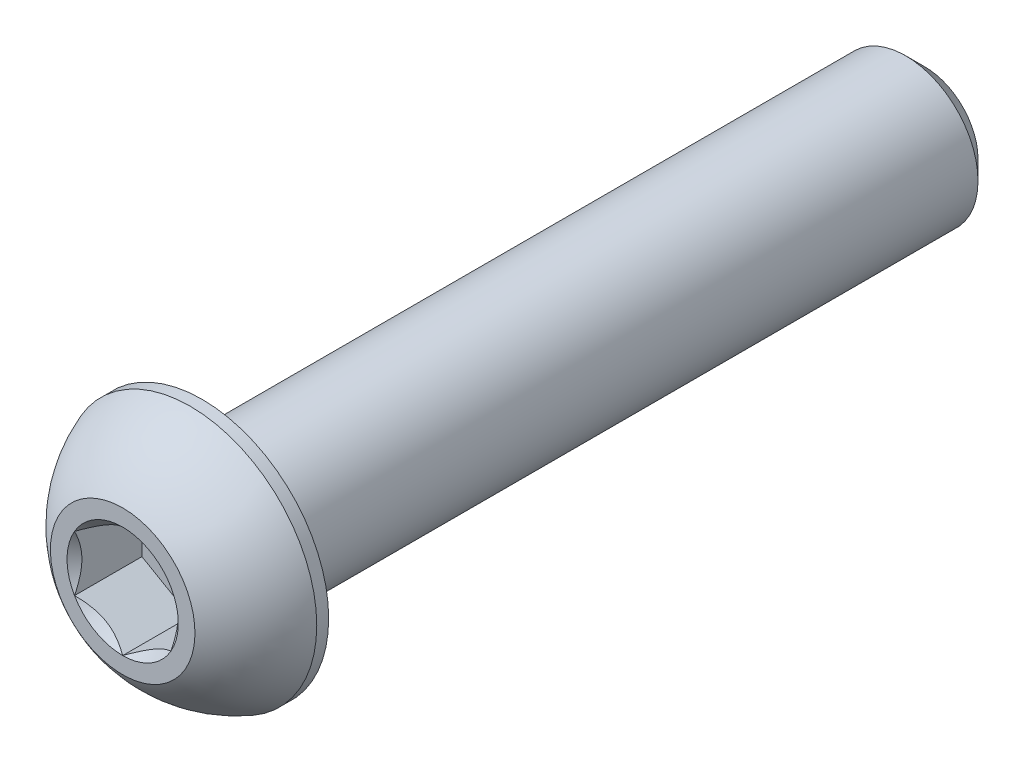
from build123d import *

# Parameters (mm, degrees)
CUT_EXTRUDE1_DEPTH = 2.8


with BuildPart() as part:
    # Sketch2 → Revolve1 (revolve)
    with BuildSketch(Plane(origin=(0, 0, 0), x_dir=(0, 0, -1), z_dir=(1, 0, 0)), mode=Mode.PRIVATE) as revolve1_sk:
        with BuildLine():
            Line((-16.65, 0), (16.65, 0))
            Line((16.65, 0), (16.65, 2.2))
            Line((16.65, 2.2), (15.85, 3))
            Line((15.85, 3), (-13.35, 3))
            Line((-13.35, 3), (-13.35, 5.25))
            Line((-13.35, 5.25), (-13.845, 5.25))
            ThreePointArc((-13.845, 5.25), (-15.433520981, 4.356906156), (-16.65, 3))
            Line((-16.65, 3), (-16.65, 0))
        make_face()
    revolve(revolve1_sk.sketch.rotate(Axis((0, 0, 16.65), (0, 0, -1)), 90), axis=Axis((0, 0, 16.65), (0, 0, -1)))

    # Sketch3 → Cut-Extrude1 (cut)
    with BuildSketch(Plane.XY.offset(16.65)):
        Polygon((0, 2.309401077), (-2, 1.154700538), (-2, -1.154700538), (0, -2.309401077), (2, -1.154700538), (2, 1.154700538), align=None)
    extrude(amount=-CUT_EXTRUDE1_DEPTH, mode=Mode.SUBTRACT)

    # Cut-Extrude2 cone 1 section (through the dimple's axis) → Cut-Extrude2 (revolve, cut)
    with BuildSketch(Plane(origin=(0, 0, 16.65), x_dir=(0, -1, 0), z_dir=(1, 0, 0))):
        Polygon((0, 0), (2.309401077, 0), (0, 2.309401077), align=None)
    revolve(axis=Axis((0, 0, 16.65), (0, 0, -1)), mode=Mode.SUBTRACT)


solid = part.part
